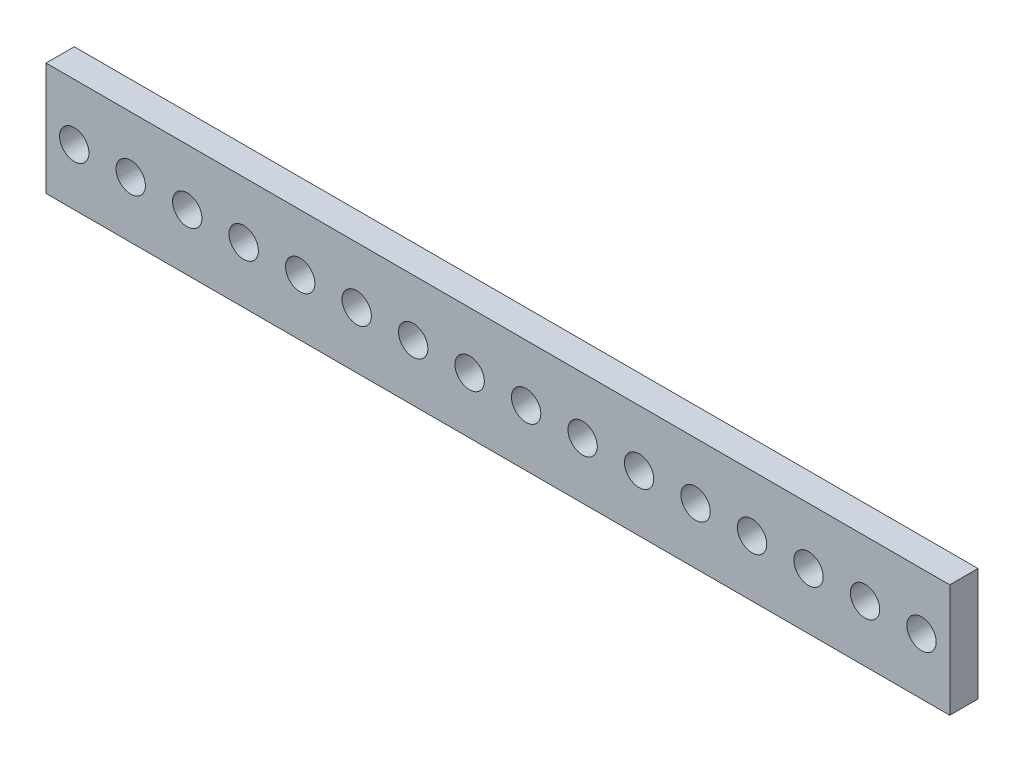
from build123d import *

# Parameters (mm, degrees)
SKETCH1_W               = 101.6
SKETCH1_H               = 12.7
BOSS_EXTRUDE3_DEPTH     = 3.175
SKETCH2_R               = 1.651
CUT_EXTRUDE1_DEPTH      = 127
CUT_EXTRUDE1_DEPTH_BACK = 127


with BuildPart() as part:
    # Sketch1 → Boss-Extrude3 (new body)
    with BuildSketch(Plane.XY):
        with Locations((50.8, 6.35)):
            Rectangle(SKETCH1_W, SKETCH1_H)
    extrude(amount=BOSS_EXTRUDE3_DEPTH)

    # Sketch2 → Cut-Extrude1 (cut, two sides)
    with BuildSketch(Plane.XY) as cut_extrude1_sk:
        with Locations((3.175, 6.35)):
            Circle(SKETCH2_R)
        with Locations((9.525, 6.35)):
            Circle(SKETCH2_R)
        with Locations((15.875, 6.35)):
            Circle(SKETCH2_R)
        with Locations((22.225, 6.35)):
            Circle(SKETCH2_R)
        with Locations((28.575, 6.35)):
            Circle(SKETCH2_R)
        with Locations((34.925, 6.35)):
            Circle(SKETCH2_R)
        with Locations((41.275, 6.35)):
            Circle(SKETCH2_R)
        with Locations((47.625, 6.35)):
            Circle(SKETCH2_R)
        with Locations((53.975, 6.35)):
            Circle(SKETCH2_R)
        with Locations((60.325, 6.35)):
            Circle(SKETCH2_R)
        with Locations((66.675, 6.35)):
            Circle(SKETCH2_R)
        with Locations((73.025, 6.35)):
            Circle(SKETCH2_R)
        with Locations((79.375, 6.35)):
            Circle(SKETCH2_R)
        with Locations((85.725, 6.35)):
            Circle(SKETCH2_R)
        with Locations((92.075, 6.35)):
            Circle(SKETCH2_R)
        with Locations((98.425, 6.35)):
            Circle(SKETCH2_R)
    extrude(amount=CUT_EXTRUDE1_DEPTH, mode=Mode.SUBTRACT)
    extrude(cut_extrude1_sk.sketch, amount=-CUT_EXTRUDE1_DEPTH_BACK, mode=Mode.SUBTRACT)


solid = part.part
